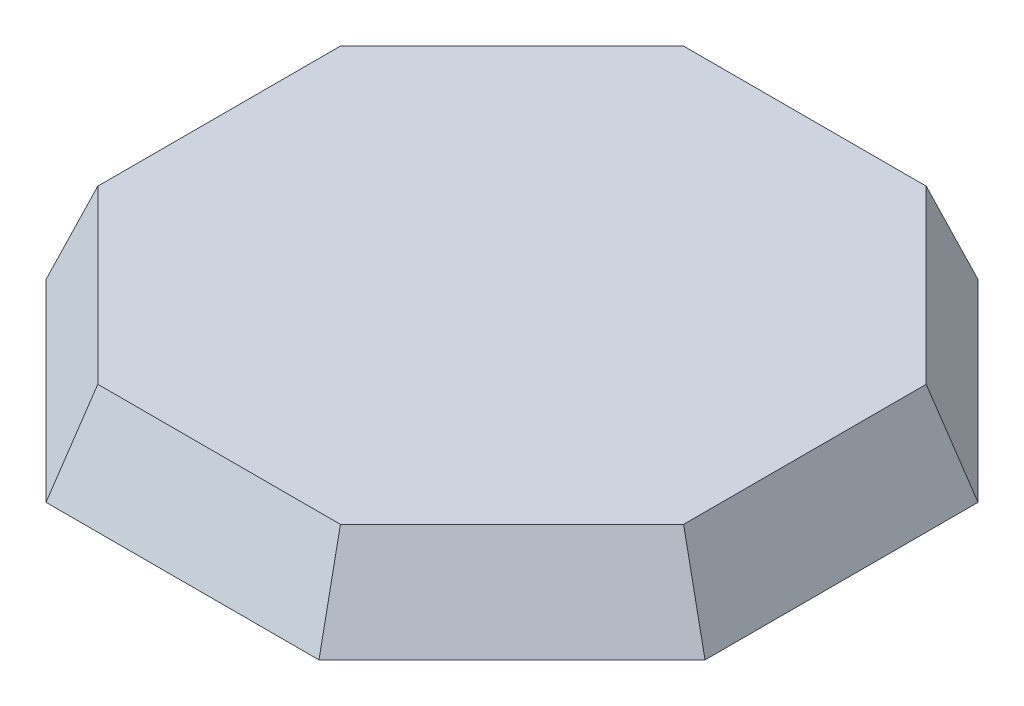
from build123d import *

# Parameters (mm, degrees)
BOSS_EXTRUDE1_DEPTH     = 25
CUT_EXTRUDE1_DEPTH      = 38.279220614
CIRPATTERN1_COUNT       = 8
SHELL2_T                = -10
BOSS_EXTRUDE2_DEPTH     = 15
SKETCH8_R               = 1.75
CUT_EXTRUDE3_DEPTH      = 3.89
SKETCH10_R              = 1.5
CUT_EXTRUDE5_DEPTH      = 10
CIRPATTERN2_COUNT       = 8
CUT_EXTRUDE7_DEPTH      = 2
CUT_EXTRUDE8_DEPTH      = 3.7
FILLET1_R               = 1
CUT_EXTRUDE9_DEPTH      = 1
SKETCH15_R              = 1.1
CUT_EXTRUDE11_DEPTH     = 4
MIRROR2_COPY_1_SKETCH_R = 1.1
MIRROR2_COPY_1_DEPTH    = 4
CUT_EXTRUDE12_DEPTH     = 2.5
SKETCH17_R              = 1
CUT_EXTRUDE13_DEPTH     = 4
CUT_EXTRUDE14_DEPTH     = 0.5
SKETCH19_R              = 3.8
CUT_EXTRUDE15_DEPTH     = 3
CIRPATTERN3_COUNT       = 8


with BuildPart() as part:
    # Sketch3 → Boss-Extrude1 (new body)
    with BuildSketch(Plane(origin=(0, 0, 0), x_dir=(1, 0, 0), z_dir=(0, 1, 0))):
        Polygon((-90, 37.279220614), (-90, -37.279220614), (0, 0), align=None)
    boss_extrude1 = extrude(amount=BOSS_EXTRUDE1_DEPTH)

    # Sketch4 → Cut-Extrude1 (cut, symmetric)
    with BuildSketch(Plane.XY):
        Polygon((-90, 25), (-90, 0), (-80, 25), align=None)
    cut_extrude1 = extrude(amount=CUT_EXTRUDE1_DEPTH, both=True, mode=Mode.SUBTRACT)

    # CirPattern1: Boss-Extrude1, Cut-Extrude1 ×8 about axis
    cirpattern1_axis = Axis((0, 0, 0), (0, 1, 0))
    for i in range(1, CIRPATTERN1_COUNT):
        add(boss_extrude1.rotate(cirpattern1_axis, i * 360 / CIRPATTERN1_COUNT))
        add(cut_extrude1.rotate(cirpattern1_axis, i * 360 / CIRPATTERN1_COUNT), mode=Mode.SUBTRACT)

    # Shell2
    shell2_openings = [part.faces().sort_by_distance(p)[0] for p in [
        (0, 0, 0),
    ]]
    offset(amount=SHELL2_T, openings=shell2_openings, kind=Kind.INTERSECTION)

    # Sketch5 → Boss-Extrude2 (add)
    with BuildSketch(Plane.XZ.offset(-15)):
        with BuildLine():
            Line((-79.229670386, -32.818004016), (-79.229670386, -26.828993349))
            ThreePointArc((-79.229670386, -26.828993349), (-70.654057407, -29.265868815), (-74.99480033, -37.052874072))
            Line((-74.99480033, -37.052874072), (-79.229670386, -32.818004016))
        make_face()
    boss_extrude2 = extrude(amount=BOSS_EXTRUDE2_DEPTH)

    # Sketch8 → Cut-Extrude3 (cut)
    with BuildSketch(Plane.XZ):
        with Locations((-75.906312549, -31.441424128)):
            Circle(SKETCH8_R)
    cut_extrude3 = extrude(amount=-CUT_EXTRUDE3_DEPTH, mode=Mode.SUBTRACT)

    # Sketch10 → Cut-Extrude5 (cut)
    with BuildSketch(Plane.XZ.offset(-3.89)):
        with Locations((-75.906312549, -31.441424128)):
            Circle(SKETCH10_R)
    cut_extrude5 = extrude(amount=-CUT_EXTRUDE5_DEPTH, mode=Mode.SUBTRACT)

    # CirPattern2: Boss-Extrude2, Cut-Extrude3, Cut-Extrude5 ×8 about axis
    cirpattern2_axis = Axis((0, 0, 0), (0, 1, 0))
    for i in range(1, CIRPATTERN2_COUNT):
        add(boss_extrude2.rotate(cirpattern2_axis, i * 360 / CIRPATTERN2_COUNT))
        add(cut_extrude3.rotate(cirpattern2_axis, i * 360 / CIRPATTERN2_COUNT), mode=Mode.SUBTRACT)
        add(cut_extrude5.rotate(cirpattern2_axis, i * 360 / CIRPATTERN2_COUNT), mode=Mode.SUBTRACT)

    # Sketch11 → Cut-Extrude7 (cut)
    with BuildSketch(Plane.XZ.offset(-15)):
        with BuildLine():
            Line((-34.358681844, -65.650070064), (34.041318156, -65.650070064))
            ThreePointArc((34.041318156, -65.650070064), (39.203197659, -63.511949566), (41.341318156, -58.350070064))
            Line((41.341318156, -58.350070064), (41.341318156, -19.050070064))
            ThreePointArc((41.341318156, -19.050070064), (39.203197659, -13.888190561), (34.041318156, -11.750070064))
            Line((34.041318156, -11.750070064), (-34.358681844, -11.750070064))
            ThreePointArc((-34.358681844, -11.750070064), (-39.520561346, -13.888190561), (-41.658681844, -19.050070064))
            Line((-41.658681844, -19.050070064), (-41.658681844, -58.350070064))
            ThreePointArc((-41.658681844, -58.350070064), (-39.520561346, -63.511949566), (-34.358681844, -65.650070064))
        make_face()
        Polygon((26.669250561, 70.01701088), (14.499741046, 57.72095305), (40.157988887, 32.326774235), (52.327498403, 44.622832065), align=None)
        Polygon((-45.807628052, 29.456027416), (-45.557628052, 30.956027416), (-50.265904305, 30.956027416), (-50.015904305, 29.456027416), (-61.961766178, 29.456027416), (-61.961766178, 13.460165542), (-63.461766178, 13.710165542), (-63.461766178, 9.001889289), (-61.961766178, 9.251889289), (-61.961766178, -6.743972584), (20.938233822, -6.743972584), (20.938233822, 10.356027416), (20.938233822, 10.513250754), (20.938233822, 12.198804078), (20.938233822, 12.356027416), (20.938233822, 29.456027416), (8.992371948, 29.456027416), (9.242371948, 30.956027416), (4.534095695, 30.956027416), (4.784095695, 29.456027416), align=None)
        with BuildLine():
            Line((45.394921968, -29.715967357), (66.654814344, -29.648319841))
            ThreePointArc((66.654814344, -29.648319841), (68.279008196, -28.969493954), (68.947484296, -27.341013079))
            Line((68.947484296, -27.341013079), (68.763251409, 30.558693813))
            ThreePointArc((68.763251409, 30.558693813), (68.084425523, 32.182887666), (66.455944648, 32.851363765))
            Line((66.455944648, 32.851363765), (45.196052273, 32.783716249))
            ThreePointArc((45.196052273, 32.783716249), (43.57185842, 32.104890363), (42.903382321, 30.476409488))
            Line((42.903382321, 30.476409488), (43.087615207, -27.423297405))
            ThreePointArc((43.087615207, -27.423297405), (43.766441094, -29.047491257), (45.394921968, -29.715967357))
        make_face()
        Polygon((8.912517718, 34.761532869), (9.383564949, 60.756265326), (-36.708868078, 61.591500425), (-37.179915309, 35.596767968), align=None)
    extrude(amount=-CUT_EXTRUDE7_DEPTH, mode=Mode.SUBTRACT)

    # Sketch13 → Cut-Extrude8 (cut)
    with BuildSketch(Plane.XZ.offset(-17)):
        with BuildLine():
            Line((34.041318156, -11.750070064), (-34.358681844, -11.750070064))
            ThreePointArc((-34.358681844, -11.750070064), (-39.520561346, -13.888190561), (-41.658681844, -19.050070064))
            Line((-41.658681844, -19.050070064), (-41.658681844, -58.350070064))
            ThreePointArc((-41.658681844, -58.350070064), (-39.520561346, -63.511949566), (-34.358681844, -65.650070064))
            Line((-34.358681844, -65.650070064), (34.041318156, -65.650070064))
            ThreePointArc((34.041318156, -65.650070064), (39.203197659, -63.511949566), (41.341318156, -58.350070064))
            Line((41.341318156, -58.350070064), (41.341318156, -19.050070064))
            ThreePointArc((41.341318156, -19.050070064), (39.203197659, -13.888190561), (34.041318156, -11.750070064))
        make_face()
    extrude(amount=-CUT_EXTRUDE8_DEPTH, mode=Mode.SUBTRACT)

    # Fillet1
    fillet1_edges = [part.edges().sort_by_distance(p)[0] for p in [
        (8.912517718, 16, 34.761532869),
        (-37.179915309, 16, 35.596767968),
        (-36.708868078, 16, 61.591500425),
        (9.383564949, 16, 60.756265326),
    ]]
    fillet(fillet1_edges, radius=FILLET1_R)

    # Sketch14 → Cut-Extrude9 (cut)
    with BuildSketch(Plane.XZ.offset(-17)):
        with BuildLine():
            Line((45.394921968, -29.715967357), (66.654814344, -29.648319841))
            ThreePointArc((66.654814344, -29.648319841), (68.279008196, -28.969493954), (68.947484296, -27.341013079))
            Line((68.947484296, -27.341013079), (68.763251409, 30.558693813))
            ThreePointArc((68.763251409, 30.558693813), (68.084425523, 32.182887666), (66.455944648, 32.851363765))
            Line((66.455944648, 32.851363765), (45.196052273, 32.783716249))
            ThreePointArc((45.196052273, 32.783716249), (43.57185842, 32.104890363), (42.903382321, 30.476409488))
            Line((42.903382321, 30.476409488), (43.087615207, -27.423297405))
            ThreePointArc((43.087615207, -27.423297405), (43.766441094, -29.047491257), (45.394921968, -29.715967357))
        make_face()
        Polygon((52.327498403, 44.622832065), (26.669250561, 70.01701088), (14.499741046, 57.72095305), (40.157988887, 32.326774235), align=None)
    extrude(amount=-CUT_EXTRUDE9_DEPTH, mode=Mode.SUBTRACT)

    # Sketch15 → Cut-Extrude11 (cut)
    with BuildSketch(Plane.XZ.offset(-18)):
        with Locations((65.616131079, 29.648675337)):
            Circle(SKETCH15_R)
    cut_extrude11 = extrude(amount=-CUT_EXTRUDE11_DEPTH, mode=Mode.SUBTRACT)

    # Mirror1: Cut-Extrude11 across plane
    add(cut_extrude11.mirror(Plane(origin=(-0.004422036, 0, 1.38973325), x_dir=(0.999994938, 0, 0.003181915), z_dir=(0.003181915, 0, -0.999994938))), mode=Mode.SUBTRACT)

    # Mirror2: Cut-Extrude11 across plane
    add(cut_extrude11.mirror(Plane(origin=(55.929855344, 0, 0.177964954), x_dir=(-0.003181915, 0, 0.999994938), z_dir=(-0.999994938, 0, -0.003181915))), mode=Mode.SUBTRACT)

    # Mirror2 copy 1 sketch → Mirror2 copy 1 (cut)
    with BuildSketch(Plane(origin=(111.850866616, 18, 3.135396408), x_dir=(-1, 0, 0), z_dir=(0, -1, 0))):
        with Locations((65.616131079, 29.648675337)):
            Circle(MIRROR2_COPY_1_SKETCH_R)
    extrude(amount=-MIRROR2_COPY_1_DEPTH, mode=Mode.SUBTRACT)

    # Sketch16 → Cut-Extrude12 (cut)
    with BuildSketch(Plane.XZ.offset(-17)):
        Polygon((4.784095695, 29.456027416), (-45.807628052, 29.456027416), (-45.557628052, 30.956027416), (-50.265904305, 30.956027416), (-50.015904305, 29.456027416), (-61.961766178, 29.456027416), (-61.961766178, 13.460165542), (-63.461766178, 13.710165542), (-63.461766178, 9.001889289), (-61.961766178, 9.251889289), (-61.961766178, -6.743972584), (20.938233822, -6.743972584), (20.938233822, 29.456027416), (8.992371948, 29.456027416), (9.242371948, 30.956027416), (4.534095695, 30.956027416), align=None)
    extrude(amount=-CUT_EXTRUDE12_DEPTH, mode=Mode.SUBTRACT)

    # Sketch17 → Cut-Extrude13 (cut)
    with BuildSketch(Plane.XZ.offset(-18)):
        with Locations((18.389142064, 57.67035938)):
            Circle(SKETCH17_R)
        with Locations((40.067163093, 36.21544376)):
            Circle(SKETCH17_R)
    extrude(amount=-CUT_EXTRUDE13_DEPTH, mode=Mode.SUBTRACT)

    # Sketch18 → Cut-Extrude14 (cut)
    with BuildSketch(Plane.XZ.offset(-17)):
        with BuildLine():
            Line((8.930635616, 35.761368726), (9.365447051, 59.756429468))
            ThreePointArc((9.365447051, 59.756429468), (9.085413197, 60.468726793), (8.383729092, 60.774383224))
            Line((8.383729092, 60.774383224), (-35.70903222, 61.573382527))
            ThreePointArc((-35.70903222, 61.573382527), (-36.421329544, 61.293348673), (-36.726985976, 60.591664568))
            Line((-36.726985976, 60.591664568), (-37.16179741, 36.596603826))
            ThreePointArc((-37.16179741, 36.596603826), (-36.881763556, 35.884306501), (-36.180079451, 35.57865007))
            Line((-36.180079451, 35.57865007), (7.912681861, 34.779650767))
            ThreePointArc((7.912681861, 34.779650767), (8.624979185, 35.059684621), (8.930635616, 35.761368726))
        make_face()
    extrude(amount=-CUT_EXTRUDE14_DEPTH, mode=Mode.SUBTRACT)

    # Sketch19 → Cut-Extrude15 (cut)
    with BuildSketch(Plane.XZ):
        with Locations((52.760655942, -66.902791566)):
            Circle(SKETCH19_R)
        with Locations((66.902791566, -52.760655942)):
            Circle(SKETCH19_R)
    cut_extrude15 = extrude(amount=-CUT_EXTRUDE15_DEPTH, mode=Mode.SUBTRACT)

    # CirPattern3: Cut-Extrude15 ×8 about axis, 2 skipped
    cirpattern3_axis = Axis((0, 0, 0), (0, 1, 0))
    add([cut_extrude15.rotate(cirpattern3_axis, i * 360 / CIRPATTERN3_COUNT) for i in range(1, CIRPATTERN3_COUNT) if i not in (3, 7)], mode=Mode.SUBTRACT)


solid = part.part
